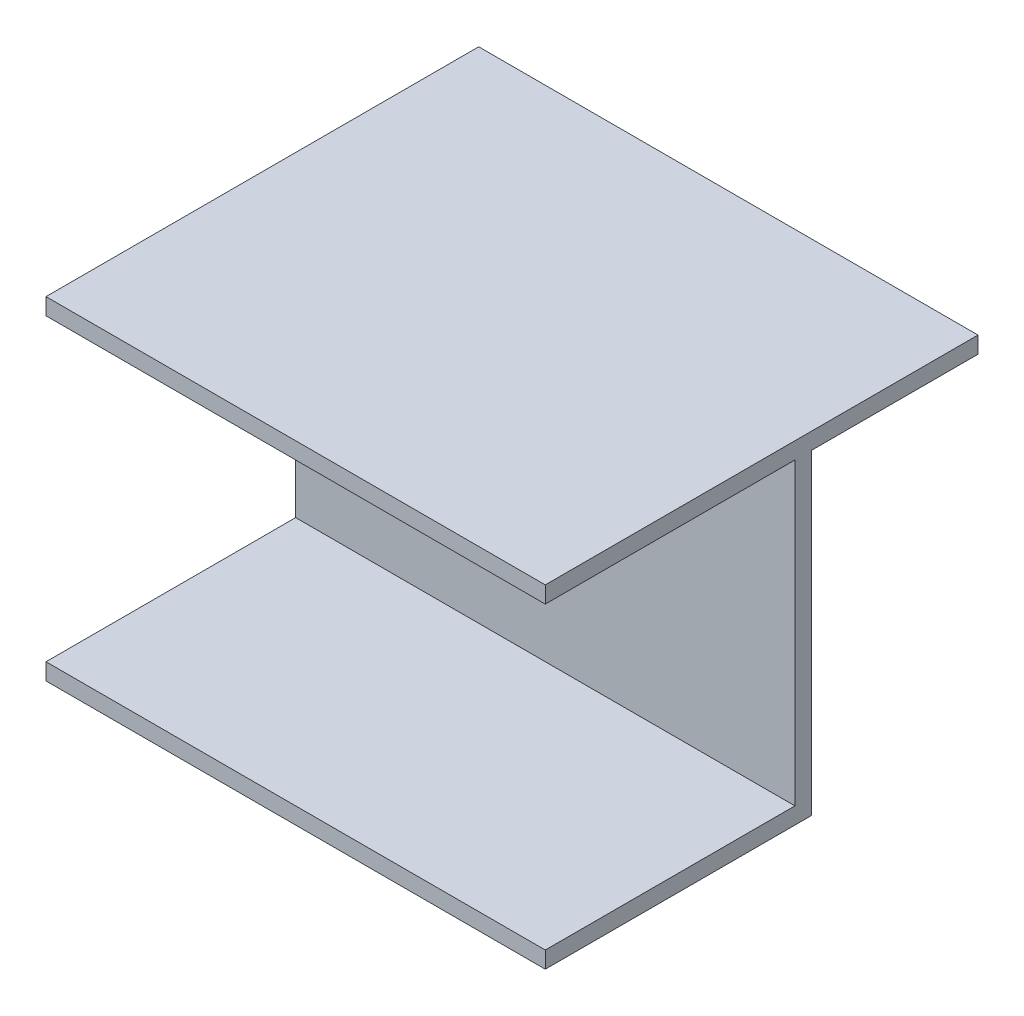
from build123d import *

# Parameters (mm, degrees)
SKETCH_1_W      = 60
SKETCH_1_H      = 40
EXTRUDE_1_DEPTH = 2
SKETCH_2_W      = 60
SKETCH_2_H      = 2
EXTRUDE_2_DEPTH = 30
SKETCH_3_W      = 60
SKETCH_3_H      = 2
EXTRUDE_3_DEPTH = 20


with BuildPart() as part:
    # 草图1 → 凸台-拉伸1 (new body)
    with BuildSketch(Plane.XY):
        with Locations((-1.578947368, -6.578947368)):
            Rectangle(SKETCH_1_W, SKETCH_1_H)
    extrude(amount=EXTRUDE_1_DEPTH)

    # 草图2 → 凸台-拉伸2 (add)
    with BuildSketch(Plane.XY.offset(2)):
        with Locations((-1.578947368, 12.421052632)):
            Rectangle(SKETCH_2_W, SKETCH_2_H)
        with Locations((-1.578947368, -25.578947368)):
            Rectangle(SKETCH_2_W, SKETCH_2_H)
    extrude(amount=EXTRUDE_2_DEPTH)

    # 草图3 → 凸台-拉伸3 (add)
    with BuildSketch(Plane(origin=(0, 0, 0), x_dir=(-1, 0, 0), z_dir=(0, 0, -1))):
        with Locations((1.578947368, 12.421052632)):
            Rectangle(SKETCH_3_W, SKETCH_3_H)
    extrude(amount=EXTRUDE_3_DEPTH)


solid = part.part
